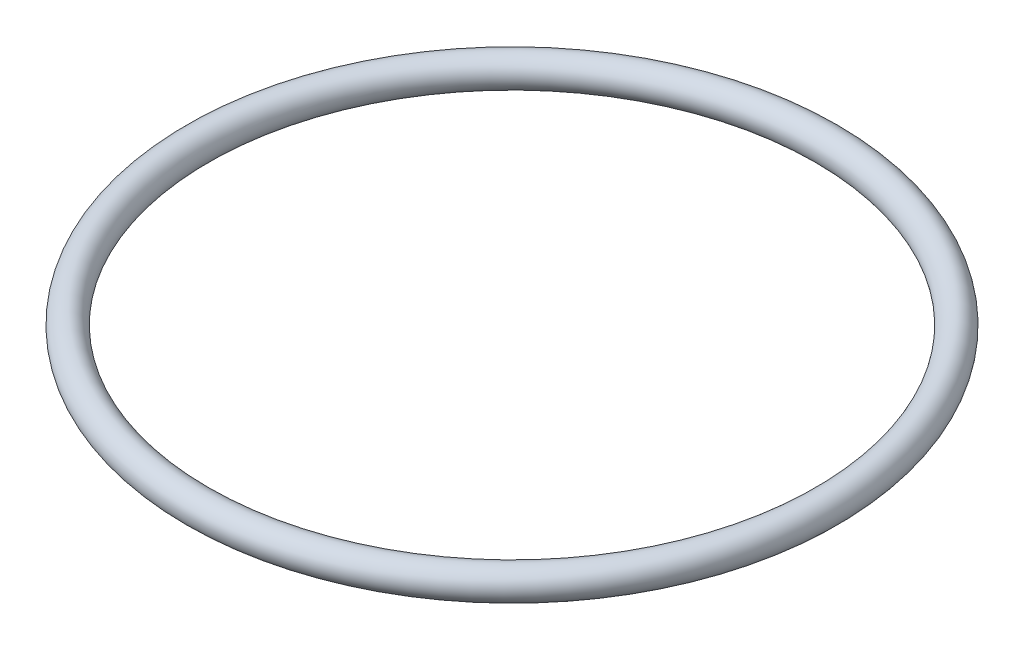
from build123d import *

# Parameters (mm, degrees)
SKETCH1_R = 1.5


with BuildPart() as part:
    # Sketch1 → Revolve1 (revolve)
    with BuildSketch(Plane.XY):
        with Locations((30.75, 0)):
            Circle(SKETCH1_R)
    revolve(axis=Axis((0, 0, 0), (0, 1, 0)))


solid = part.part
